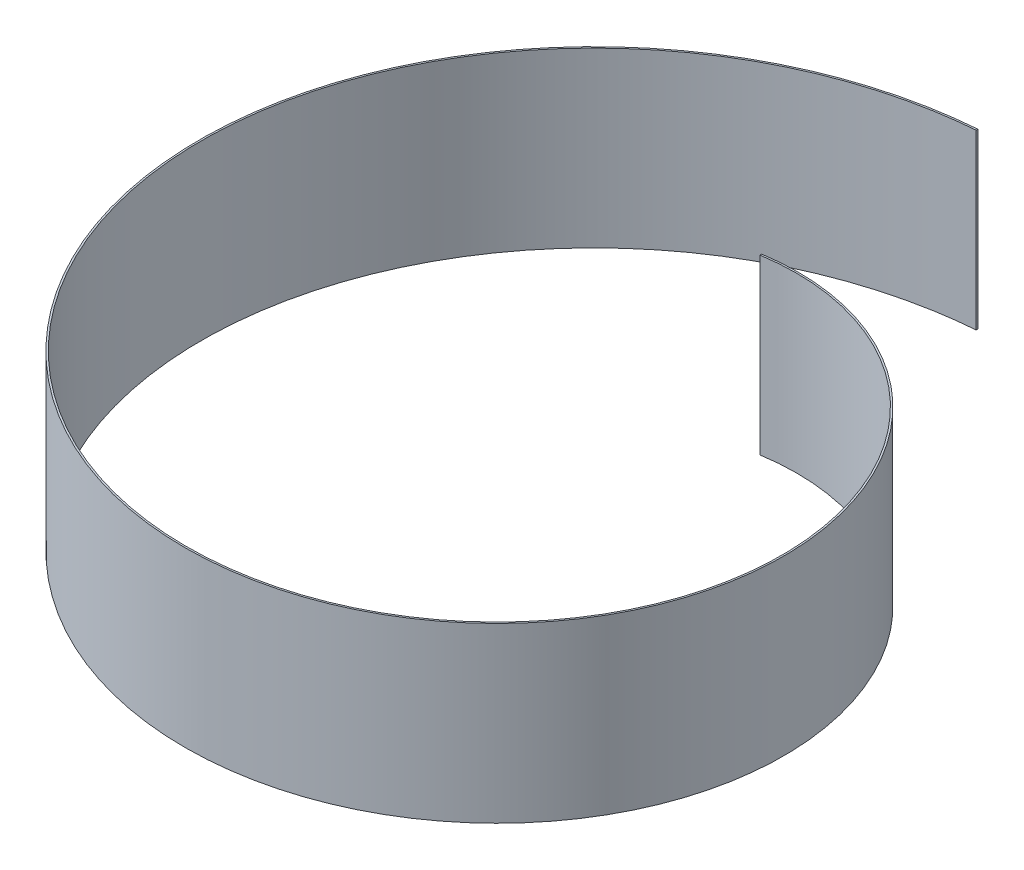
from build123d import *

# Parameters (mm, degrees)
SKETCH4_W = 2
SKETCH4_H = 200


with BuildPart() as part:
    # Sweep1: sweep along a curve in space
    with BuildLine() as sweep1_path:
        add(Edge.make_bspline(
            [(0, 0, -250), (8.181230869, 0, -251.302083333), (16.490485858, 0, -252.202239115), (33.283843215, 0, -253.165004898), (41.767918014, 0, -253.227597369), (58.825529276, 0, -252.489812839), (67.399036198, 0, -251.689421172), (84.546849552, 0, -249.209035813), (93.121124768, 0, -247.529030536), (110.179448676, 0, -243.28197111), (118.663464802, 0, -240.714908644), (135.448838644, 0, -234.695772919), (143.750162786, 0, -231.243694762), (160.077308396, 0, -223.466249466), (168.103095642, 0, -219.140880964), (183.786929167, 0, -209.638354886), (191.44494095, 0, -204.461199558), (206.302623467, 0, -193.286364859), (213.502259812, 0, -187.288691386), (227.355264371, 0, -174.513728488), (234.008598689, 0, -167.736448609), (246.684770924, 0, -153.452592355), (252.707575824, 0, -145.946029132), (264.043165005, 0, -130.262996352), (269.35591753, 0, -122.086543468), (279.197554898, 0, -105.131744499), (283.726409621, 0, -96.353418486), (291.933011092, 0, -78.270957675), (295.610729717, 0, -68.966846184), (302.055300528, 0, -49.916318794), (304.822126933, 0, -40.169929234), (309.39344656, 0, -20.325024564), (311.197916667, 0, -10.226538586), (313.802083333, 0, 10.226538586), (314.601759746, 0, 20.581098128), (315.163575101, 0, 41.445373487), (314.925697135, 0, 51.955055437), (313.389873123, 0, 73.024682105), (312.091913646, 0, 83.584591073), (308.424085306, 0, 104.646879334), (306.054206696, 0, 115.149221353), (300.241736515, 0, 135.986781136), (296.799139049, 0, 146.321960485), (288.851700557, 0, 166.714935063), (284.346857616, 0, 176.772691135), (274.29678815, 0, 196.501059175), (268.751563779, 0, 206.171631657), (256.653978741, 0, 225.017553673), (250.101624339, 0, 234.192863818), (236.034287727, 0, 251.943048248), (228.519315892, 0, 260.517883668), (212.582264503, 0, 276.965947186), (204.160199387, 0, 284.839137372), (186.475120704, 0, 299.787933778), (177.212125552, 0, 306.863503462), (157.921492035, 0, 320.127395411), (147.893875928, 0, 326.315682935), (127.159841084, 0, 337.722731058), (116.453448267, 0, 342.941459114), (94.45651255, 0, 352.335503566), (83.165999013, 0, 356.510790002), (60.103456218, 0, 363.753400295), (48.331459506, 0, 366.820697137), (24.415636833, 0, 371.79296719), (12.271846303, 0, 373.697916667), (-12.271846303, 0, 376.302083333), (-24.671710397, 0, 377.001280376), (-49.606903759, 0, 377.162145305), (-62.14219286, 0, 376.623796902), (-87.223834934, 0, 374.289933407), (-99.770145948, 0, 372.49440612), (-124.746909116, 0, 367.639134798), (-137.177317938, 0, 364.579382855), (-161.794113597, 0, 357.201501919), (-173.980456169, 0, 352.883369455), (-197.981031483, 0, 343.007628195), (-209.795219484, 0, 337.45002047), (-232.924809953, 0, 325.127326834), (-244.240167671, 0, 318.362246594), (-266.248178179, 0, 303.669602597), (-276.940786686, 0, 295.742049119), (-297.583473029, 0, 278.782210595), (-307.533507523, 0, 269.749940398), (-326.576630001, 0, 250.650800517), (-335.669676056, 0, 240.583950166), (-352.891096632, 0, 219.497649054), (-361.0194311, 0, 208.478221971), (-376.211625816, 0, 185.579987719), (-383.275448339, 0, 173.701208389), (-396.247907217, 0, 149.18793767), (-402.156508607, 0, 136.553478049), (-412.73799604, 0, 110.642067425), (-417.410850286, 0, 97.365151842), (-425.451500061, 0, 70.290593641), (-428.81926734, 0, 56.492989778), (-434.192487821, 0, 28.506249102), (-436.197916667, 0, 14.31715402), (-438.802083333, 0, -14.31715402), (-439.400801007, 0, -28.762322666), (-439.160715508, 0, -57.768434031), (-438.321896668, 0, -72.329330283), (-435.189993691, 0, -101.422987763), (-432.896898594, 0, -115.955700823), (-426.854184291, 0, -144.846938898), (-423.104559014, 0, -159.205414524), (-414.161267324, 0, -187.601446057), (-408.96759986, 0, -201.638951853), (-397.163555833, 0, -229.247127902), (-390.553183323, 0, -242.817747834), (-375.957865518, 0, -269.348560731), (-367.972929409, 0, -282.308703686), (-350.685226452, 0, -307.478802685), (-341.3824739, 0, -319.688709553), (-321.530133463, 0, -343.223897809), (-310.980564904, 0, -354.549131378), (-288.719336532, 0, -376.187312816), (-277.007700944, 0, -386.50021474), (-252.520177403, 0, -405.994259486), (-239.744318391, 0, -415.175358738), (-213.238483403, 0, -432.295856222), (-199.508540849, 0, -440.235213744), (-171.216034255, 0, -454.773083377), (-156.653507831, 0, -461.3715581), (-126.8276223, 0, -473.140488514), (-111.564304671, 0, -478.31091057), (-80.477731064, 0, -487.149599827), (-64.65452005, 0, -490.817837544), (-32.596861371, 0, -496.592008451), (-16.362461737, 0, -498.697916667), (0, 0, -500)],
            knots=[0, 0, 0, 0, 0.015625, 0.015625, 0.03125, 0.03125, 0.046875, 0.046875, 0.0625, 0.0625, 0.078125, 0.078125, 0.09375, 0.09375, 0.109375, 0.109375, 0.125, 0.125, 0.140625, 0.140625, 0.15625, 0.15625, 0.171875, 0.171875, 0.1875, 0.1875, 0.203125, 0.203125, 0.21875, 0.21875, 0.234375, 0.234375, 0.25, 0.25, 0.265625, 0.265625, 0.28125, 0.28125, 0.296875, 0.296875, 0.3125, 0.3125, 0.328125, 0.328125, 0.34375, 0.34375, 0.359375, 0.359375, 0.375, 0.375, 0.390625, 0.390625, 0.40625, 0.40625, 0.421875, 0.421875, 0.4375, 0.4375, 0.453125, 0.453125, 0.46875, 0.46875, 0.484375, 0.484375, 0.5, 0.5, 0.515625, 0.515625, 0.53125, 0.53125, 0.546875, 0.546875, 0.5625, 0.5625, 0.578125, 0.578125, 0.59375, 0.59375, 0.609375, 0.609375, 0.625, 0.625, 0.640625, 0.640625, 0.65625, 0.65625, 0.671875, 0.671875, 0.6875, 0.6875, 0.703125, 0.703125, 0.71875, 0.71875, 0.734375, 0.734375, 0.75, 0.75, 0.765625, 0.765625, 0.78125, 0.78125, 0.796875, 0.796875, 0.8125, 0.8125, 0.828125, 0.828125, 0.84375, 0.84375, 0.859375, 0.859375, 0.875, 0.875, 0.890625, 0.890625, 0.90625, 0.90625, 0.921875, 0.921875, 0.9375, 0.9375, 0.953125, 0.953125, 0.96875, 0.96875, 0.984375, 0.984375, 1, 1, 1, 1], degree=3))
    # Sketch4 → Sweep1 (sweep)
    with BuildSketch(Plane(origin=(0, 0, 0), x_dir=(0, 0, -1), z_dir=(1, 0, 0))):
        with Locations((249, 100)):
            Rectangle(SKETCH4_W, SKETCH4_H)
    sweep(path=sweep1_path.line, is_frenet=True)


solid = part.part
